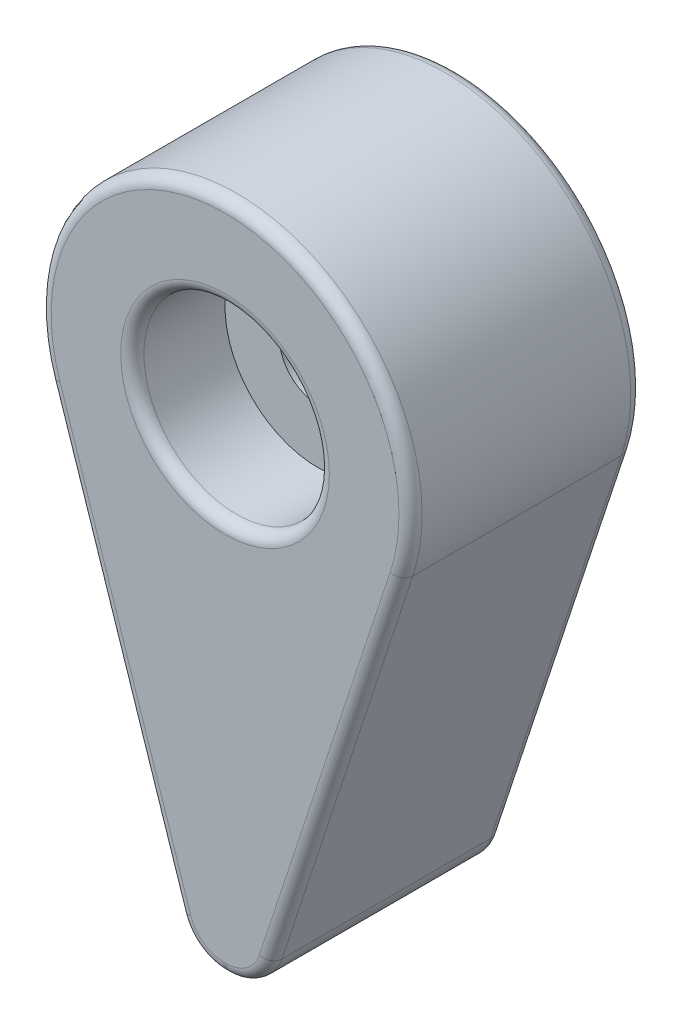
from build123d import *

# Parameters (mm, degrees)
EXTRUDE_1_DEPTH     = 10
FILLET_1_R          = 2
SKETCH_4_R          = 4
CUT_EXTRUDE_1_DEPTH = 4
M4X0_71_D           = 3.3
FILLET_3_R          = 0.5


with BuildPart() as part:
    # Эскиз1 → Бобышка-Вытянуть1 (new body)
    with BuildSketch(Plane.XY):
        with BuildLine():
            Line((-1.5, -21), (-7.597720185, -2.504924749))
            ThreePointArc((-7.597720185, -2.504924749), (0, 8), (7.597720185, -2.504924749))
            Line((7.597720185, -2.504924749), (1.5, -21))
            Line((1.5, -21), (-1.5, -21))
        make_face()
    extrude(amount=EXTRUDE_1_DEPTH)

    # Скругление1
    fillet_1_edges = [part.edges().sort_by_distance(p)[0] for p in [
        (-1.5, -21, 5),
        (1.5, -21, 5),
    ]]
    fillet(fillet_1_edges, radius=FILLET_1_R)

    # Эскиз4 → Вырез-Вытянуть1 (cut)
    with BuildSketch(Plane.XY.offset(10)):
        Circle(SKETCH_4_R)
    extrude(amount=-CUT_EXTRUDE_1_DEPTH, mode=Mode.SUBTRACT)

    # Отверстие обработанное метчиком M4x0.71 (through all)
    with Locations(Plane.XY.offset(6)):
        with Locations((0, 0)):
            Hole(M4X0_71_D / 2)

    # Скругление3
    fillet_3_edges = [part.edges().sort_by_distance(p)[0] for p in [
        (0, 8, 10),
        (-4.77532194, -11.065577968, 10),
        (4.77532194, -11.065577968, 0),
        (4.77532194, -11.065577968, 10),
        (0, -21, 0),
        (-1.225572491, -20.620565083, 0),
        (1.225572491, -20.620565083, 0),
        (0, -21, 10),
        (-1.225572491, -20.620565083, 10),
        (1.225572491, -20.620565083, 10),
        (-4, 0, 10),
        (1.65, 0, 0),
        (-4.77532194, -11.065577968, 0),
        (0, 8, 0),
    ]]
    fillet(fillet_3_edges, radius=FILLET_3_R)


solid = part.part
